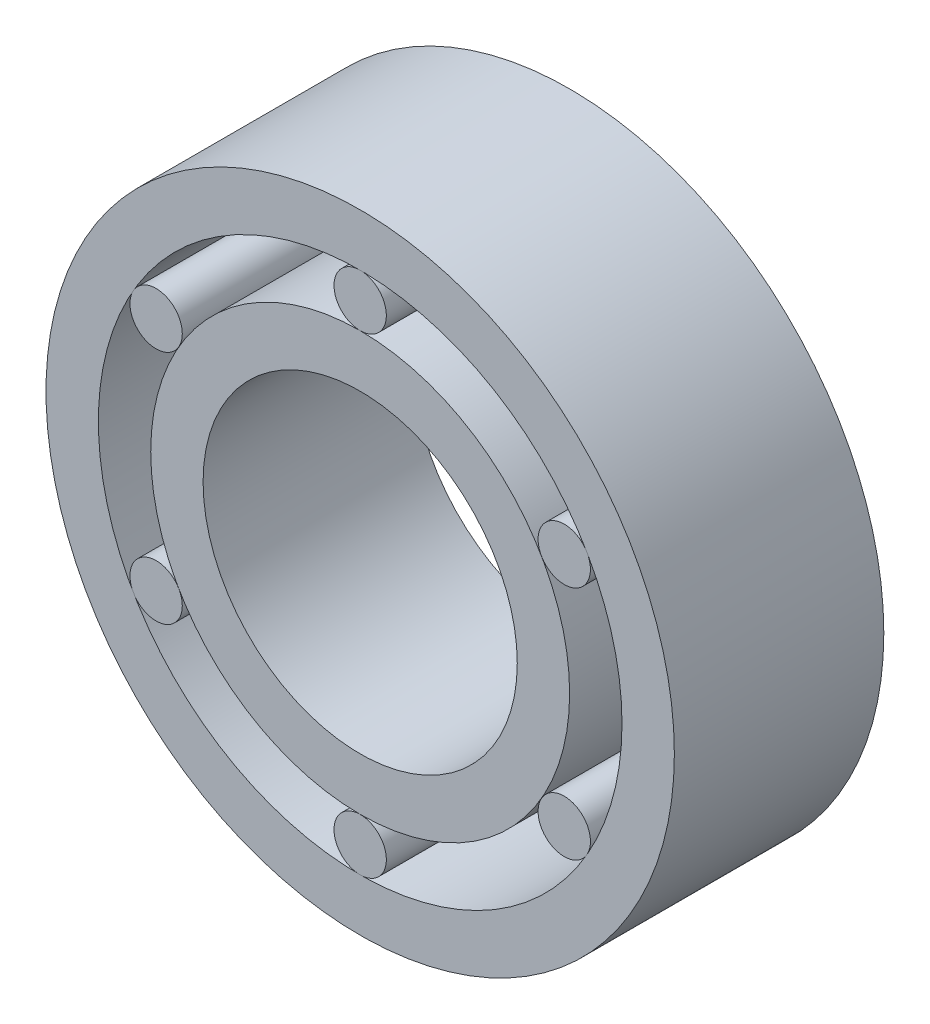
from build123d import *

# Parameters (mm, degrees)
SKETCH_1_R        = 4
SKETCH_1_R_2      = 3
EXTRUDE_1_DEPTH   = 4
SKETCH_1_R_3      = 0.5
EXTRUDE_1_2_DEPTH = 4
SKETCH_1_R_4      = 6
SKETCH_1_R_5      = 5
EXTRUDE_1_3_DEPTH = 4
EXTRUDE_1_4_DEPTH = 4
EXTRUDE_1_5_DEPTH = 4
EXTRUDE_1_6_DEPTH = 4
EXTRUDE_1_7_DEPTH = 4
EXTRUDE_1_8_DEPTH = 4


with BuildPart() as part:
    # 草图1 → 凸台-拉伸1 (new body)
    with BuildSketch(Plane.XY):
        Circle(SKETCH_1_R)
        Circle(SKETCH_1_R_2, mode=Mode.SUBTRACT)
    extrude(amount=EXTRUDE_1_DEPTH)


with BuildPart() as body_2:
    # 草图1 → Extrude 1 2 (new body)
    with BuildSketch(Plane.XY):
        with Locations((0, 4.5)):
            Circle(SKETCH_1_R_3)
    extrude(amount=EXTRUDE_1_2_DEPTH)


with BuildPart() as body_3:
    # 草图1 → Extrude 1 3 (new body)
    with BuildSketch(Plane.XY):
        Circle(SKETCH_1_R_4)
        Circle(SKETCH_1_R_5, mode=Mode.SUBTRACT)
    extrude(amount=EXTRUDE_1_3_DEPTH)


with BuildPart() as body_4:
    # 草图1 → Extrude 1 4 (new body)
    with BuildSketch(Plane.XY):
        with Locations((-3.897114317, 2.25)):
            Circle(SKETCH_1_R_3)
    extrude(amount=EXTRUDE_1_4_DEPTH)


with BuildPart() as body_5:
    # 草图1 → Extrude 1 5 (new body)
    with BuildSketch(Plane.XY):
        with Locations((3.897114317, 2.25)):
            Circle(SKETCH_1_R_3)
    extrude(amount=EXTRUDE_1_5_DEPTH)


with BuildPart() as body_6:
    # 草图1 → Extrude 1 6 (new body)
    with BuildSketch(Plane.XY):
        with Locations((3.897114317, -2.25)):
            Circle(SKETCH_1_R_3)
    extrude(amount=EXTRUDE_1_6_DEPTH)


with BuildPart() as body_7:
    # 草图1 → Extrude 1 7 (new body)
    with BuildSketch(Plane.XY):
        with Locations((0, -4.5)):
            Circle(SKETCH_1_R_3)
    extrude(amount=EXTRUDE_1_7_DEPTH)


with BuildPart() as body_8:
    # 草图1 → Extrude 1 8 (new body)
    with BuildSketch(Plane.XY):
        with Locations((-3.897114317, -2.25)):
            Circle(SKETCH_1_R_3)
    extrude(amount=EXTRUDE_1_8_DEPTH)


solid = Compound([part.part, body_2.part, body_3.part, body_4.part, body_5.part, body_6.part, body_7.part, body_8.part])
